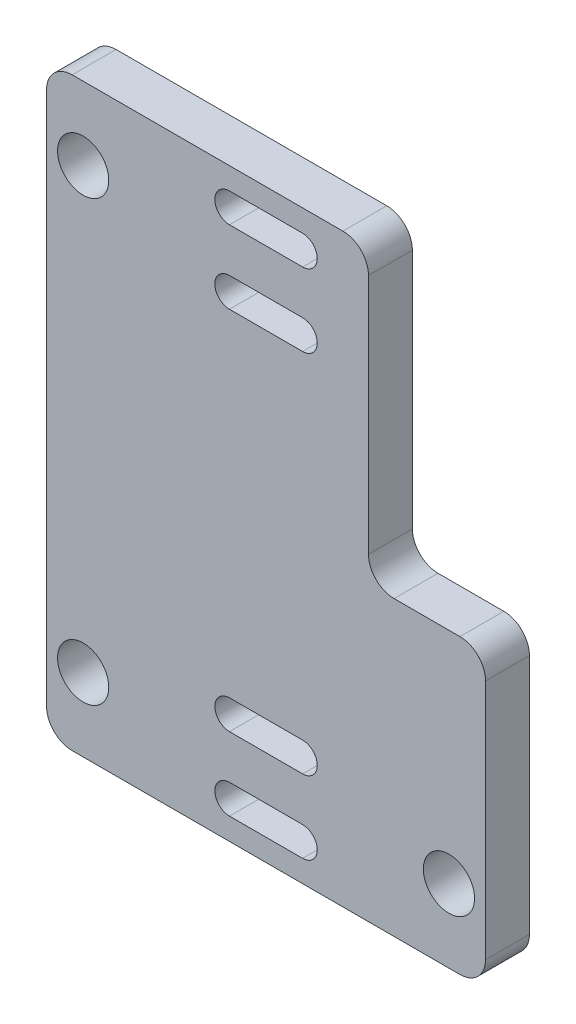
from build123d import *

# Parameters (mm, degrees)
ESQUISSE1_R        = 1.75
BOSS_EXTRU_1_DEPTH = 3
CONG_1_R           = 1.75


with BuildPart() as part:
    # Esquisse1 → Boss.-Extru.1 (new body)
    with BuildSketch(Plane.XY):
        Polygon((-15, -20), (15, -20), (15, 0), (7, 0), (7, 20), (-15, 20), align=None)
        with Locations((12.5, -15)):
            Circle(ESQUISSE1_R, mode=Mode.SUBTRACT)
        with Locations((-12.5, -15)):
            Circle(ESQUISSE1_R, mode=Mode.SUBTRACT)
        with Locations((-12.5, 15)):
            Circle(ESQUISSE1_R, mode=Mode.SUBTRACT)
        with BuildLine():
            ThreePointArc((2.5, 16.5), (3.5, 17.5), (2.5, 18.5))
            Line((2.5, 18.5), (-2.5, 18.5))
            ThreePointArc((-2.5, 18.5), (-3.5, 17.5), (-2.5, 16.5))
            Line((-2.5, 16.5), (2.5, 16.5))
        make_face(mode=Mode.SUBTRACT)
        with BuildLine():
            ThreePointArc((2.5, -13.5), (3.5, -12.5), (2.5, -11.5))
            Line((2.5, -11.5), (-2.5, -11.5))
            ThreePointArc((-2.5, -11.5), (-3.5, -12.5), (-2.5, -13.5))
            Line((-2.5, -13.5), (2.5, -13.5))
        make_face(mode=Mode.SUBTRACT)
        with BuildLine():
            Line((-2.5, -16.5), (2.5, -16.5))
            ThreePointArc((2.5, -16.5), (3.5, -17.5), (2.5, -18.5))
            Line((2.5, -18.5), (-2.5, -18.5))
            ThreePointArc((-2.5, -18.5), (-3.5, -17.5), (-2.5, -16.5))
        make_face(mode=Mode.SUBTRACT)
        with BuildLine():
            Line((-2.5, 13.5), (2.5, 13.5))
            ThreePointArc((2.5, 13.5), (3.5, 12.5), (2.5, 11.5))
            Line((2.5, 11.5), (-2.5, 11.5))
            ThreePointArc((-2.5, 11.5), (-3.5, 12.5), (-2.5, 13.5))
        make_face(mode=Mode.SUBTRACT)
    extrude(amount=BOSS_EXTRU_1_DEPTH)

    # Congé1
    cong_1_edges = [part.edges().sort_by_distance(p)[0] for p in [
        (-15, -20, 1.5),
        (-15, 20, 1.5),
        (7, 20, 1.5),
        (7, 0, 1.5),
        (15, 0, 1.5),
        (15, -20, 1.5),
    ]]
    fillet(cong_1_edges, radius=CONG_1_R)


solid = part.part
